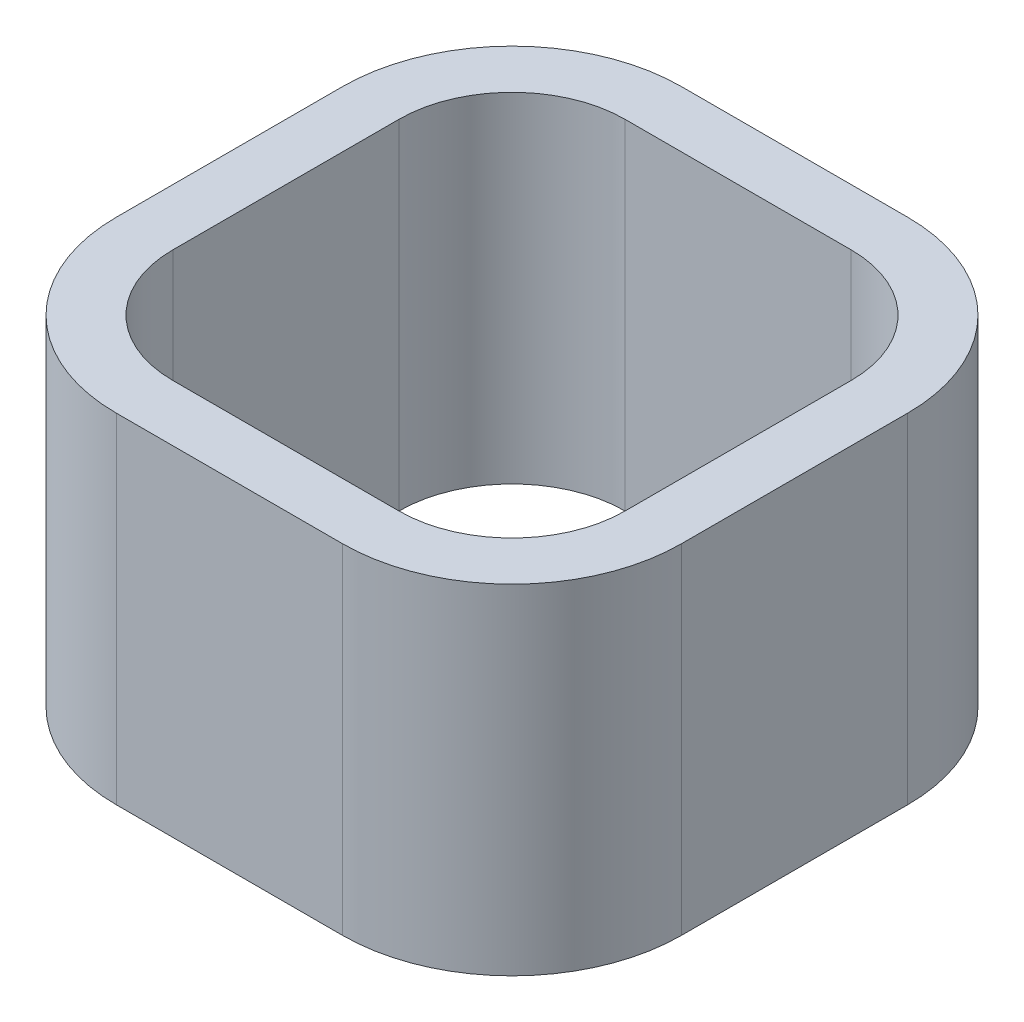
from build123d import *

# Parameters (mm, degrees)
SKIZZE1_W                            = 5
SKIZZE1_H                            = 5
SKIZZE1_W_2                          = 4
SKIZZE1_H_2                          = 4
AUFSATZ_LINEAR_AUSTRAGEN1_DEPTH      = 3
VERRUNDUNG1_R                        = 1
VERRUNDUNG2_R                        = 1.5
F_0_3_0_3_DURCHMESSER_BOHRUNG3_D     = 0.3
F_0_3_0_3_DURCHMESSER_BOHRUNG3_DEPTH = 0.01
F_0_3_0_3_DURCHMESSER_BOHRUNG3_TIP   = 0.15


with BuildPart() as part:
    # Skizze1 → Aufsatz-Linear austragen1 (new body)
    with BuildSketch(Plane(origin=(0, 0, 0), x_dir=(1, 0, 0), z_dir=(0, 1, 0))):
        Rectangle(SKIZZE1_W, SKIZZE1_H)
        Rectangle(SKIZZE1_W_2, SKIZZE1_H_2, mode=Mode.SUBTRACT)
    extrude(amount=AUFSATZ_LINEAR_AUSTRAGEN1_DEPTH)

    # Verrundung1
    verrundung1_edges = [part.edges().sort_by_distance(p)[0] for p in [
        (2, 1.5, 2),
        (2, 1.5, -2),
        (-2, 1.5, -2),
        (-2, 1.5, 2),
    ]]
    fillet(verrundung1_edges, radius=VERRUNDUNG1_R)

    # Verrundung2
    verrundung2_edges = [part.edges().sort_by_distance(p)[0] for p in [
        (2.5, 1.5, 2.5),
        (-2.5, 1.5, 2.5),
        (-2.5, 1.5, -2.5),
        (2.5, 1.5, -2.5),
    ]]
    fillet(verrundung2_edges, radius=VERRUNDUNG2_R)

    # Ø0.3 (0.3) Durchmesser Bohrung3
    with Locations(Plane(origin=(-2.060660172, 0, -2.060660172), x_dir=(-0.707106781, 0, 0.707106781), z_dir=(-0.707106781, 0, -0.707106781))):
        with Locations((0, 1.5)):
            Hole(F_0_3_0_3_DURCHMESSER_BOHRUNG3_D / 2, depth=F_0_3_0_3_DURCHMESSER_BOHRUNG3_DEPTH)
            with Locations((0, 0, -(F_0_3_0_3_DURCHMESSER_BOHRUNG3_DEPTH + F_0_3_0_3_DURCHMESSER_BOHRUNG3_TIP / 2))):  # 90° drill point
                Cone(0, F_0_3_0_3_DURCHMESSER_BOHRUNG3_D / 2, F_0_3_0_3_DURCHMESSER_BOHRUNG3_TIP, mode=Mode.SUBTRACT)


solid = part.part
